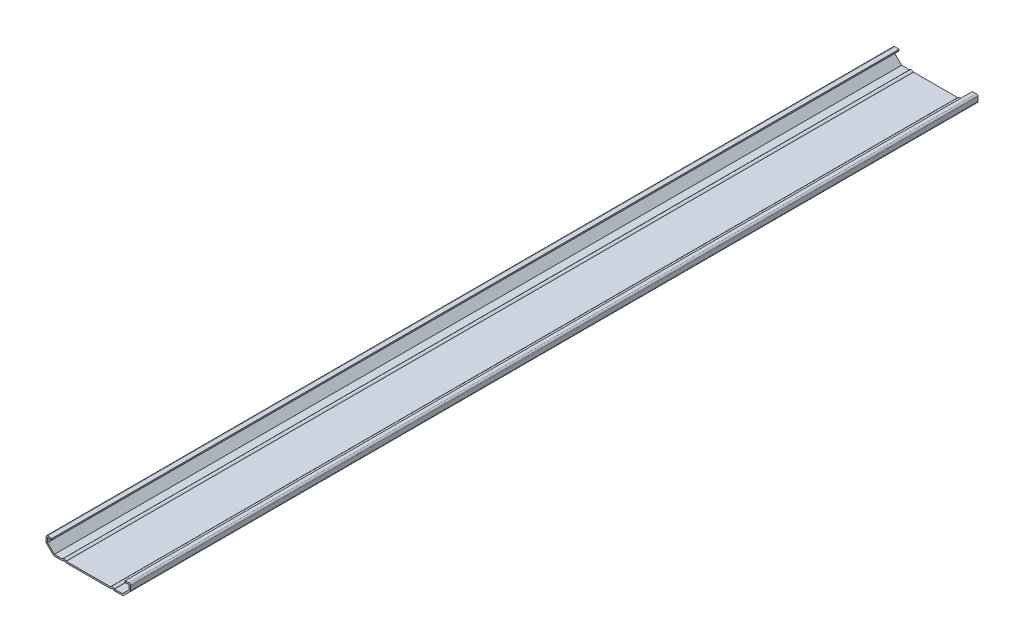
from build123d import *

# Parameters (mm, degrees)
EXTRUDE_THIN1_DEPTH = 698.5
FILLET1_R           = 1.27


with BuildPart() as part:
    # Sketch1 → Extrude-Thin1 (new body)
    with BuildSketch(Plane.XY):
        with BuildLine():
            Line((30.1625, 11.509375), (34.925, 11.90625))
            Line((34.925, 11.90625), (34.925, 6.35))
            Line((34.925, 6.35), (28.575, 0))
            Line((28.575, 0), (20.6375, 0))
            ThreePointArc((20.6375, 0), (19.84375, 0.79375), (19.05, 0))
            Line((19.05, 0), (-19.05, 0))
            ThreePointArc((-19.05, 0), (-19.84375, 0.79375), (-20.6375, 0))
            Line((-20.6375, 0), (-28.575, 0))
            Line((-28.575, 0), (-34.925, 6.35))
            Line((-34.925, 6.35), (-34.925, 11.90625))
            Line((-34.925, 11.90625), (-30.1625, 11.509375))
            Line((-30.1625, 11.509375), (-30.267967759, 10.243761887))
            Line((-30.267967759, 10.243761887), (-33.655, 10.526014574))
            Line((-33.655, 10.526014574), (-33.655, 6.876051224))
            Line((-33.655, 6.876051224), (-28.048948776, 1.27))
            Line((-28.048948776, 1.27), (-21.470453434, 1.27))
            ThreePointArc((-21.470453434, 1.27), (-19.84375, 2.06375), (-18.217046566, 1.27))
            Line((-18.217046566, 1.27), (18.217046566, 1.27))
            ThreePointArc((18.217046566, 1.27), (19.84375, 2.06375), (21.470453434, 1.27))
            Line((21.470453434, 1.27), (28.048948776, 1.27))
            Line((28.048948776, 1.27), (33.655, 6.876051224))
            Line((33.655, 6.876051224), (33.655, 10.526014574))
            Line((33.655, 10.526014574), (30.267967759, 10.243761887))
            Line((30.267967759, 10.243761887), (30.1625, 11.509375))
        make_face()
    extrude(amount=-EXTRUDE_THIN1_DEPTH)

    # Fillet1
    fillet1_edges = [part.edges().sort_by_distance(p)[0] for p in [
        (34.925, 11.90625, -349.25),
        (34.925, 6.35, -349.25),
        (28.575, 0, -349.25),
        (20.6375, 0, -349.25),
        (19.05, 0, -349.25),
        (-19.05, 0, -349.25),
        (-20.6375, 0, -349.25),
        (-28.575, 0, -349.25),
        (-34.925, 6.35, -349.25),
        (-34.925, 11.90625, -349.25),
    ]]
    fillet(fillet1_edges, radius=FILLET1_R)


solid = part.part
